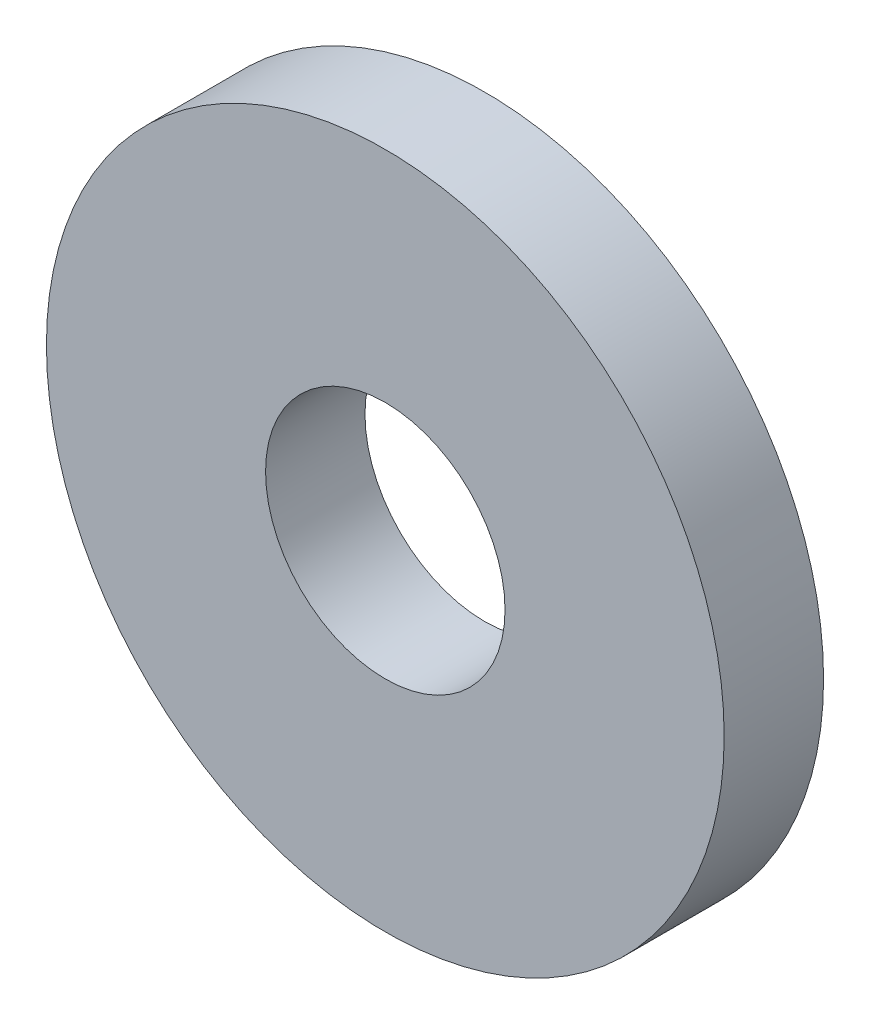
from build123d import *

# Parameters (mm, degrees)
SKETCH3_R                = 7.5
SKETCH3_R_2              = 2.65
BOSS_EXTRUDE1_DEPTH      = 1.1
BOSS_EXTRUDE1_DEPTH_BACK = 1.1


with BuildPart() as part:
    # Sketch3 → Boss-Extrude1 (new body, two sides)
    with BuildSketch(Plane.XY) as boss_extrude1_sk:
        Circle(SKETCH3_R)
        Circle(SKETCH3_R_2, mode=Mode.SUBTRACT)
    extrude(amount=BOSS_EXTRUDE1_DEPTH)
    extrude(boss_extrude1_sk.sketch, amount=-BOSS_EXTRUDE1_DEPTH_BACK)


solid = part.part
